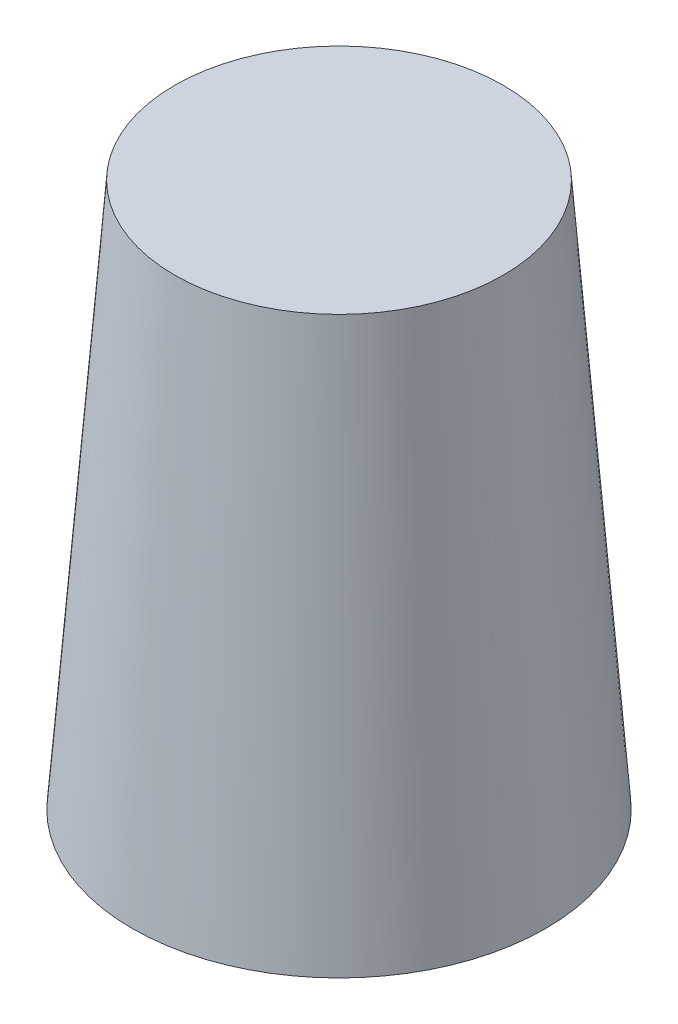
from build123d import *

# Parameters (mm, degrees)
SKETCH2_R           = 35
BOSS_EXTRUDE1_DEPTH = 1.5
FILLET1_R           = 5


with BuildPart() as part:
    # Sketch1 → Revolve1 (revolve)
    with BuildSketch(Plane.XY):
        Polygon((35, 53.703703704), (44, -62.296296296), (42.62962963, -62.296296296), (33.5, 53.703703704), align=None)
    revolve(axis=Axis((0, 53.703703704, 0), (0, -1, 0)))

    # Sketch2 → Boss-Extrude1 (add)
    with BuildSketch(Plane(origin=(0, 53.703703704, 0), x_dir=(1, 0, 0), z_dir=(0, 1, 0))):
        Circle(SKETCH2_R)
    extrude(amount=-BOSS_EXTRUDE1_DEPTH)

    # Fillet1
    fillet1_edges = [part.edges().sort_by_distance(p)[0] for p in [
        (-33.618055556, 52.203703704, 0),
    ]]
    fillet(fillet1_edges, radius=FILLET1_R)


solid = part.part
